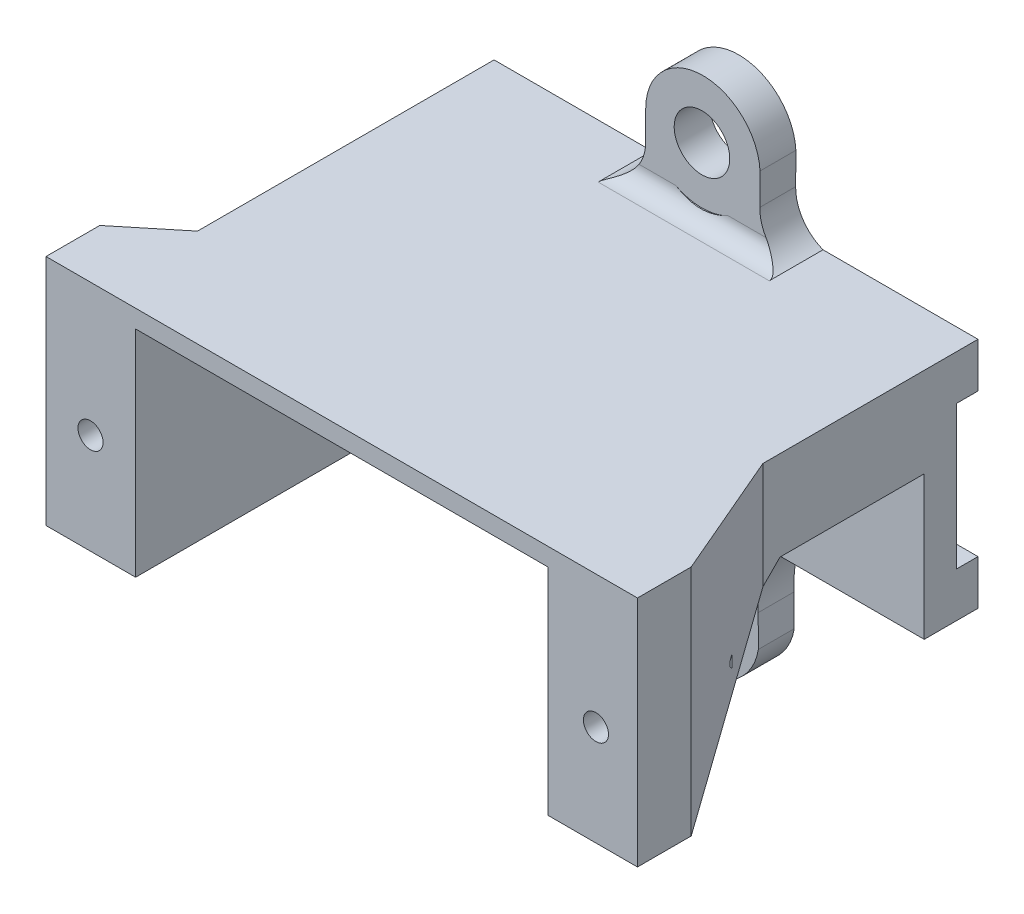
from build123d import *

# Parameters (mm, degrees)
SKETCH1_W           = 26.999950409
SKETCH1_H           = 3
BOSS_EXTRUDE1_DEPTH = 12
CUT_EXTRUDE1_DEPTH  = 11.5
BOSS_EXTRUDE2_DEPTH = 1
SKETCH7_R           = 0.7
CUT_EXTRUDE2_DEPTH  = 6
SKETCH8_R           = 1.549809906
BOSS_EXTRUDE3_DEPTH = 2
SKETCH11_W          = 30.763753833
SKETCH11_H          = 8
CUT_EXTRUDE3_DEPTH  = 1.2
FILLET1_R           = 1
SKETCH12_R          = 3.153602023
CUT_EXTRUDE4_DEPTH  = 10
CUT_EXTRUDE5_DEPTH  = 2
SKETCH14_R          = 0.7
BOSS_EXTRUDE4_DEPTH = 1


with BuildPart() as part:
    # Sketch1 → Boss-Extrude1 (new body)
    with BuildSketch(Plane(origin=(0, 0, 0), x_dir=(1, 0, 0), z_dir=(0, 1, 0))):
        with Locations((-4.128207024, 7.928244269)):
            Rectangle(SKETCH1_W, SKETCH1_H)
        Polygon((7.371810524, -11.571754957), (7.371810524, 4.428244174), (-15.628224572, 4.428244174), (-15.628224572, -11.571754957), (-15.728224572, -11.571754957), (-20.628203209, -11.571754957), (-20.628203209, -9.571756491), (-17.628182229, -7.119161332), (-17.628182229, 6.428244269), (9.37176818, 6.428244269), (9.37176818, -2.571755344), (12.371848766, -9.571756491), (12.371848766, -11.571754957), (7.471810524, -11.571754957), align=None)
    extrude(amount=BOSS_EXTRUDE1_DEPTH)

    # Sketch4 → Cut-Extrude1 (cut)
    with BuildSketch(Plane(origin=(12.371848766, 0, 0), x_dir=(0, 0, -1), z_dir=(1, 0, 0))):
        Polygon((4.428244174, 0), (4.428244174, 8.000016212), (-1.618738598, 8.000016212), (-9.571756491, 0), (-11.571754957, 0), align=None)
    extrude(amount=-CUT_EXTRUDE1_DEPTH, mode=Mode.SUBTRACT)

    # Sketch5 → Boss-Extrude2 (add)
    with BuildSketch(Plane(origin=(0, 12, 0), x_dir=(1, 0, 0), z_dir=(0, 1, 0))):
        Polygon((-20.628203209, -9.571756491), (-20.628203209, -11.571754957), (12.371848766, -11.571754957), (12.371848766, -9.571756491), (9.37176818, -2.571755344), (9.37176818, 9.428244269), (-17.628182229, 9.428244269), (-17.628182229, -7.119161332), align=None)
    extrude(amount=BOSS_EXTRUDE2_DEPTH)

    # Sketch7 → Cut-Extrude2 (cut)
    with BuildSketch(Plane.XY.offset(11.571754957)):
        with Locations((-18.144630941, 5.602586011)):
            Circle(SKETCH7_R)
        with Locations((10.055363141, 5.602566371)):
            Circle(SKETCH7_R)
    extrude(amount=-CUT_EXTRUDE2_DEPTH, mode=Mode.SUBTRACT)

    # Sketch8 → Boss-Extrude3 (add)
    with BuildSketch(Plane(origin=(0, 0, -9.428244269), x_dir=(-1, 0, 0), z_dir=(0, 0, -1))):
        with BuildLine():
            ThreePointArc((7.167350646, 16.881210895), (4.06111535, 20.071343328), (0.789350976, 17.051210792))
            Line((0.789350976, 17.051210792), (0.801312783, 15.286719843))
            ThreePointArc((0.801312783, 15.286719843), (0.398304036, 13.90328737), (-0.724359486, 13))
            Line((-0.724359486, 13), (8.821641956, 13))
            ThreePointArc((8.821641956, 13), (7.624453215, 13.872256527), (7.167350646, 15.281209887))
            Line((7.167350646, 15.281209887), (7.167350646, 16.881210895))
        make_face()
        with Locations((4.030375515, 16.793532247)):
            Circle(SKETCH8_R, mode=Mode.SUBTRACT)
        with BuildLine():
            Line((8.821641956, 0), (-0.724359486, 0))
            ThreePointArc((-0.724359486, 0), (0.554106373, -1.994843204), (0.893224509, -4.339810848))
            Line((0.893224509, -4.339810848), (0.881225349, -6.109811753))
            ThreePointArc((0.881225349, -6.109811753), (4.004145214, -8.784221579), (7.170605746, -6.16150846))
            Line((7.170605746, -6.16150846), (7.170605746, -4.561507453))
            ThreePointArc((7.170605746, -4.561507453), (7.476553675, -2.092695462), (8.821641956, 0))
        make_face()
        with Locations((4.030375515, -5.593063946)):
            Circle(SKETCH8_R, mode=Mode.SUBTRACT)
    extrude(amount=-BOSS_EXTRUDE3_DEPTH)

    # Sketch11 → Cut-Extrude3 (cut)
    with BuildSketch(Plane(origin=(0, 0, -9.428244269), x_dir=(-1, 0, 0), z_dir=(0, 0, -1))):
        with Locations((4.128177222, 6.5)):
            Rectangle(SKETCH11_W, SKETCH11_H)
    extrude(amount=-CUT_EXTRUDE3_DEPTH, mode=Mode.SUBTRACT)

    # Fillet1
    fillet1_edges = [part.edges().sort_by_distance(p)[0] for p in [
        (-4.048641235, 13, -7.428244269),
        (-4.048641235, 0, -7.428244269),
    ]]
    fillet(fillet1_edges, radius=FILLET1_R)

    # Sketch12 → Cut-Extrude4 (cut)
    with BuildSketch(Plane.XY.offset(-7.428244269)):
        with Locations((-4.030375515, 16.793532247)):
            Circle(SKETCH12_R)
    extrude(amount=CUT_EXTRUDE4_DEPTH, mode=Mode.SUBTRACT)

    # Sketch13 → Cut-Extrude5 (cut)
    with BuildSketch(Plane.XY.offset(-4.428244174)):
        Polygon((-15.628224572, 0), (-15.628224572, 12), (7.371810524, 12), (7.371810524, 8.000016212), (9.37176818, 8.000016212), (9.37176818, 0), (7.371810524, 0), align=None)
    extrude(amount=-CUT_EXTRUDE5_DEPTH, mode=Mode.SUBTRACT)

    # Sketch14 → Boss-Extrude4 (add)
    with BuildSketch(Plane.XY.offset(11.571754957)):
        Polygon((-20.628203209, 0), (-20.628203209, 13), (12.371848766, 13), (12.371848766, 0), (7.371810524, 0), (7.371810524, 12), (-15.628224572, 12), (-15.628224572, 0), align=None)
        with Locations((-18.144630941, 5.602586011)):
            Circle(SKETCH14_R, mode=Mode.SUBTRACT)
        with Locations((10.055363141, 5.602566371)):
            Circle(SKETCH14_R, mode=Mode.SUBTRACT)
    extrude(amount=BOSS_EXTRUDE4_DEPTH)


solid = part.part
